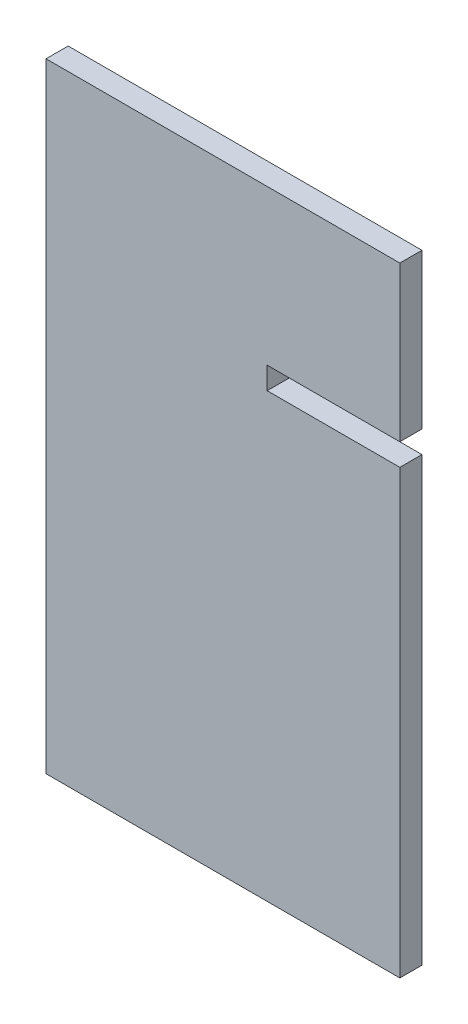
from build123d import *

# Parameters (mm, degrees)
BOSS_EXTRU_1_DEPTH = 5


with BuildPart() as part:
    # Esquisse1 → Boss.-Extru.1 (new body)
    with BuildSketch(Plane.XY):
        Polygon((80, 140), (80, 105), (50, 105), (50, 100), (80, 100), (80, 0), (0, 0), (0, 140), align=None)
    extrude(amount=BOSS_EXTRU_1_DEPTH)


solid = part.part
